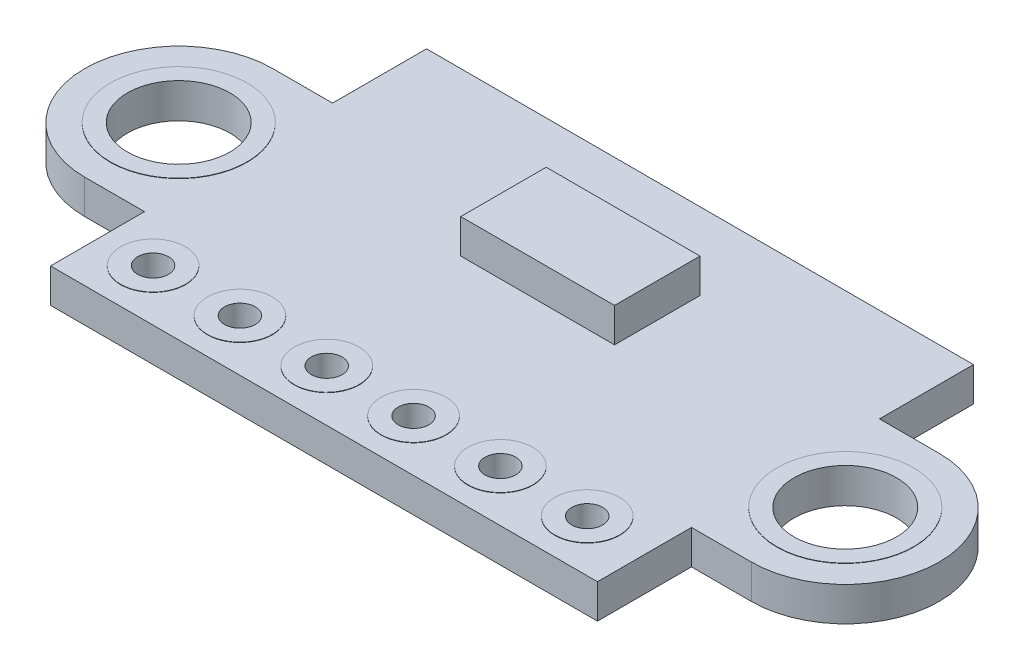
from build123d import *

# Parameters (mm, degrees)
SKETCH_1_R      = 0.45
SKETCH_1_R_2    = 1.5
EXTRUDE_1_DEPTH = 1
EXTRUDE_START   = -0.01
SKETCH_1_3_R    = 2
SKETCH_1_3_R_2  = 1.5
SKETCH_1_3_R_3  = 0.95
SKETCH_1_3_R_4  = 0.45
EXTRUDE_2_DEPTH = 1.02
SKETCH_2_W      = 4.5
SKETCH_2_H      = 2.5
EXTRUDE_3_DEPTH = 1
SKETCH_3_W      = 1.6
SKETCH_3_H      = 0.85
SKETCH_3_W_2    = 0.85
SKETCH_3_H_2    = 1.6
EXTRUDE_4_DEPTH = 0.8
SKETCH_3_3_W    = 1.8
SKETCH_3_3_H    = 3
SKETCH_3_3_W_2  = 0.85
SKETCH_3_3_H_2  = 1.6
EXTRUDE_5_DEPTH = 0.5
SKETCH_3_4_W    = 3
SKETCH_3_4_H    = 1.5
SKETCH_3_4_W_2  = 2
SKETCH_3_4_H_2  = 1.2
EXTRUDE_6_DEPTH = 1


with BuildPart() as part:
    # Эскиз1 → Бобышка-Вытянуть1 (new body)
    with BuildSketch(Plane(origin=(0, 0, 0), x_dir=(1, 0, 0), z_dir=(0, 1, 0))):
        with BuildLine():
            Line((-8, -5.5), (8, -5.5))
            Line((8, -5.5), (8, -2.75))
            Line((8, -2.75), (9.75, -2.75))
            ThreePointArc((9.75, -2.75), (12.5, 0), (9.75, 2.75))
            Line((9.75, 2.75), (8, 2.75))
            Line((8, 2.75), (8, 5.5))
            Line((8, 5.5), (-8, 5.5))
            Line((-8, 5.5), (-8, 2.75))
            Line((-8, 2.75), (-9.75, 2.75))
            ThreePointArc((-9.75, 2.75), (-12.5, 0), (-9.75, -2.75))
            Line((-9.75, -2.75), (-8, -2.75))
            Line((-8, -2.75), (-8, -5.5))
        make_face()
        with Locations((-6.5, -4)):
            Circle(SKETCH_1_R, mode=Mode.SUBTRACT)
        with Locations((-3.96, -4)):
            Circle(SKETCH_1_R, mode=Mode.SUBTRACT)
        with Locations((-1.42, -4)):
            Circle(SKETCH_1_R, mode=Mode.SUBTRACT)
        with Locations((1.12, -4)):
            Circle(SKETCH_1_R, mode=Mode.SUBTRACT)
        with Locations((3.66, -4)):
            Circle(SKETCH_1_R, mode=Mode.SUBTRACT)
        with Locations((6.2, -4)):
            Circle(SKETCH_1_R, mode=Mode.SUBTRACT)
        with Locations((-9.75, 0)):
            Circle(SKETCH_1_R_2, mode=Mode.SUBTRACT)
        with Locations((9.75, 0)):
            Circle(SKETCH_1_R_2, mode=Mode.SUBTRACT)
    extrude(amount=EXTRUDE_1_DEPTH)

    # Эскиз1<3> → Бобышка-Вытянуть2 (add)
    # profile 1 of 8: a face of its own
    with BuildSketch(Plane(origin=(0, 0, 0), x_dir=(1, 0, 0), z_dir=(0, 1, 0)).offset(EXTRUDE_START)):
        with Locations((-9.75, 0)):
            Circle(SKETCH_1_3_R)
        with Locations((-9.75, 0)):
            Circle(SKETCH_1_3_R_2, mode=Mode.SUBTRACT)
    # profile 2 of 8: a face of its own
    with BuildSketch(Plane(origin=(0, 0, 0), x_dir=(1, 0, 0), z_dir=(0, 1, 0)).offset(EXTRUDE_START)):
        with Locations((9.75, 0)):
            Circle(SKETCH_1_3_R)
        with Locations((9.75, 0)):
            Circle(SKETCH_1_3_R_2, mode=Mode.SUBTRACT)
    # profile 3 of 8: a face of its own
    with BuildSketch(Plane(origin=(0, 0, 0), x_dir=(1, 0, 0), z_dir=(0, 1, 0)).offset(EXTRUDE_START)):
        with Locations((-6.5, -4)):
            Circle(SKETCH_1_3_R_3)
        with Locations((-6.5, -4)):
            Circle(SKETCH_1_3_R_4, mode=Mode.SUBTRACT)
    # profile 4 of 8: a face of its own
    with BuildSketch(Plane(origin=(0, 0, 0), x_dir=(1, 0, 0), z_dir=(0, 1, 0)).offset(EXTRUDE_START)):
        with Locations((-3.96, -4)):
            Circle(SKETCH_1_3_R_3)
        with Locations((-3.96, -4)):
            Circle(SKETCH_1_3_R_4, mode=Mode.SUBTRACT)
    # profile 5 of 8: a face of its own
    with BuildSketch(Plane(origin=(0, 0, 0), x_dir=(1, 0, 0), z_dir=(0, 1, 0)).offset(EXTRUDE_START)):
        with Locations((-1.42, -4)):
            Circle(SKETCH_1_3_R_3)
        with Locations((-1.42, -4)):
            Circle(SKETCH_1_3_R_4, mode=Mode.SUBTRACT)
    # profile 6 of 8: a face of its own
    with BuildSketch(Plane(origin=(0, 0, 0), x_dir=(1, 0, 0), z_dir=(0, 1, 0)).offset(EXTRUDE_START)):
        with Locations((1.12, -4)):
            Circle(SKETCH_1_3_R_3)
        with Locations((1.12, -4)):
            Circle(SKETCH_1_3_R_4, mode=Mode.SUBTRACT)
    # profile 7 of 8: a face of its own
    with BuildSketch(Plane(origin=(0, 0, 0), x_dir=(1, 0, 0), z_dir=(0, 1, 0)).offset(EXTRUDE_START)):
        with Locations((3.66, -4)):
            Circle(SKETCH_1_3_R_3)
        with Locations((3.66, -4)):
            Circle(SKETCH_1_3_R_4, mode=Mode.SUBTRACT)
    # profile 8 of 8: a face of its own
    with BuildSketch(Plane(origin=(0, 0, 0), x_dir=(1, 0, 0), z_dir=(0, 1, 0)).offset(EXTRUDE_START)):
        with Locations((6.2, -4)):
            Circle(SKETCH_1_3_R_3)
        with Locations((6.2, -4)):
            Circle(SKETCH_1_3_R_4, mode=Mode.SUBTRACT)
    extrude(amount=EXTRUDE_2_DEPTH)

    # Эскиз2 → Бобышка-Вытянуть3 (add)
    with BuildSketch(Plane(origin=(0, 1, 0), x_dir=(1, 0, 0), z_dir=(0, 1, 0))):
        with Locations((0, 2)):
            Rectangle(SKETCH_2_W, SKETCH_2_H)
    extrude(amount=EXTRUDE_3_DEPTH)

    # Эскиз3 → Бобышка-Вытянуть4 (add)
    with BuildSketch(Plane.XZ):
        with Locations((-5.2, 1.875)):
            Rectangle(SKETCH_3_W, SKETCH_3_H)
        with Locations((-1.69, -3.7)):
            Rectangle(SKETCH_3_W_2, SKETCH_3_H_2)
        with Locations((0, -3.7)):
            Rectangle(SKETCH_3_W_2, SKETCH_3_H_2)
        with Locations((1.69, -3.7)):
            Rectangle(SKETCH_3_W_2, SKETCH_3_H_2)
    extrude(amount=EXTRUDE_4_DEPTH)

    # Эскиз3<3> → Бобышка-Вытянуть5 (add)
    with BuildSketch(Plane.XZ):
        with Locations((-2.1, 1)):
            Rectangle(SKETCH_3_3_W, SKETCH_3_3_H)
        with Locations((5.075, -0.7)):
            Rectangle(SKETCH_3_3_W_2, SKETCH_3_3_H_2)
        with Locations((6.575, -0.7)):
            Rectangle(SKETCH_3_3_W_2, SKETCH_3_3_H_2)
    extrude(amount=EXTRUDE_5_DEPTH)

    # Эскиз3<4> → Бобышка-Вытянуть6 (add)
    with BuildSketch(Plane.XZ):
        with Locations((-5.5, -1.25)):
            Rectangle(SKETCH_3_4_W, SKETCH_3_4_H)
        with Locations((1.5, 0.9)):
            Rectangle(SKETCH_3_4_W_2, SKETCH_3_4_H_2)
    extrude(amount=EXTRUDE_6_DEPTH)


solid = part.part
